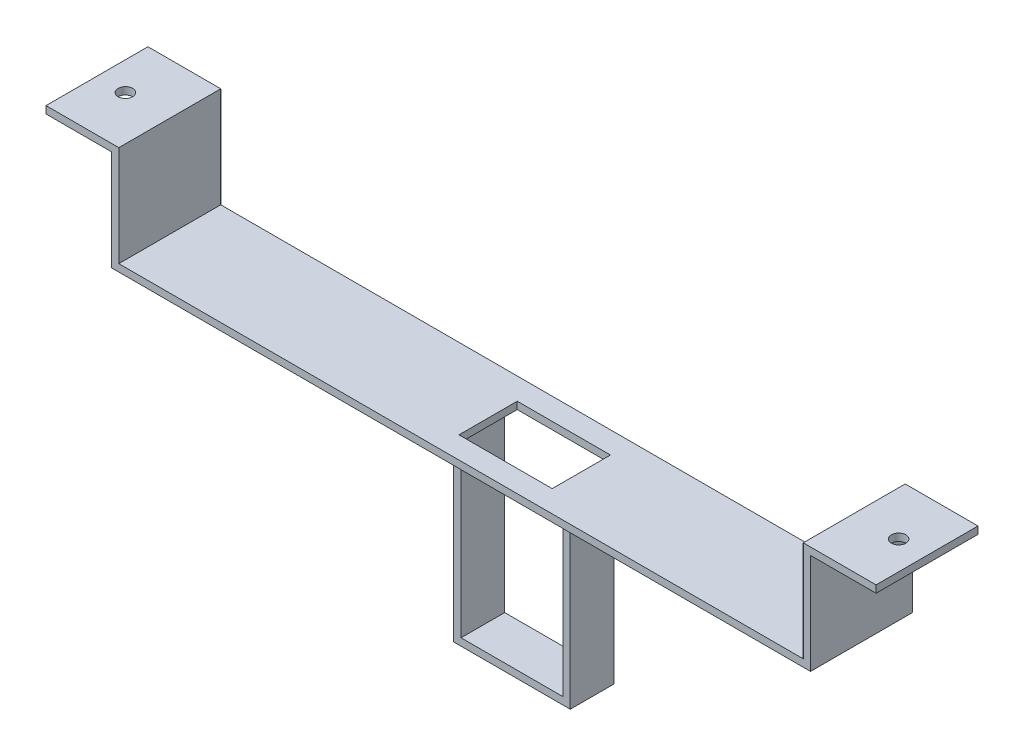
from build123d import *

# Parameters (mm, degrees)
BOSS_EXTRUDE1_DEPTH = 35
SKETCH2_R           = 2.5
SKETCH2_W           = 32
SKETCH2_H           = 20
CUT_EXTRUDE1_DEPTH  = 90
BOSS_EXTRUDE2_DEPTH = 7.5


with BuildPart() as part:
    # Sketch1 → Boss-Extrude1 (new body)
    with BuildSketch(Plane.XY):
        Polygon((117.5, 0), (-117.5, 0), (-117.5, 34.5), (-142.5, 34.5), (-142.5, 32), (-120, 32), (-120, -2.5), (120, -2.5), (120, 32), (142.5, 32), (142.5, 34.5), (117.5, 34.5), align=None)
    extrude(amount=BOSS_EXTRUDE1_DEPTH)

    # Sketch2 → Cut-Extrude1 (cut)
    with BuildSketch(Plane(origin=(0, 34.5, 0), x_dir=(1, 0, 0), z_dir=(0, 1, 0))):
        with Locations((-132.75, -17.5)):
            Circle(SKETCH2_R)
        with Locations((132.75, -17.5)):
            Circle(SKETCH2_R)
        with Locations((7.8, -17.5)):
            Rectangle(SKETCH2_W, SKETCH2_H)
    extrude(amount=-CUT_EXTRUDE1_DEPTH, mode=Mode.SUBTRACT)

    # Sketch4 → Boss-Extrude2 (add, symmetric)
    with BuildSketch(Plane.XY.offset(17.5)):
        Polygon((-12.5, -2.5), (-12.5, -65), (27.5, -65), (27.5, -2.5), (25, -2.5), (25, -62.5), (-10, -62.5), (-10, -2.5), align=None)
    extrude(amount=BOSS_EXTRUDE2_DEPTH, both=True)


solid = part.part
